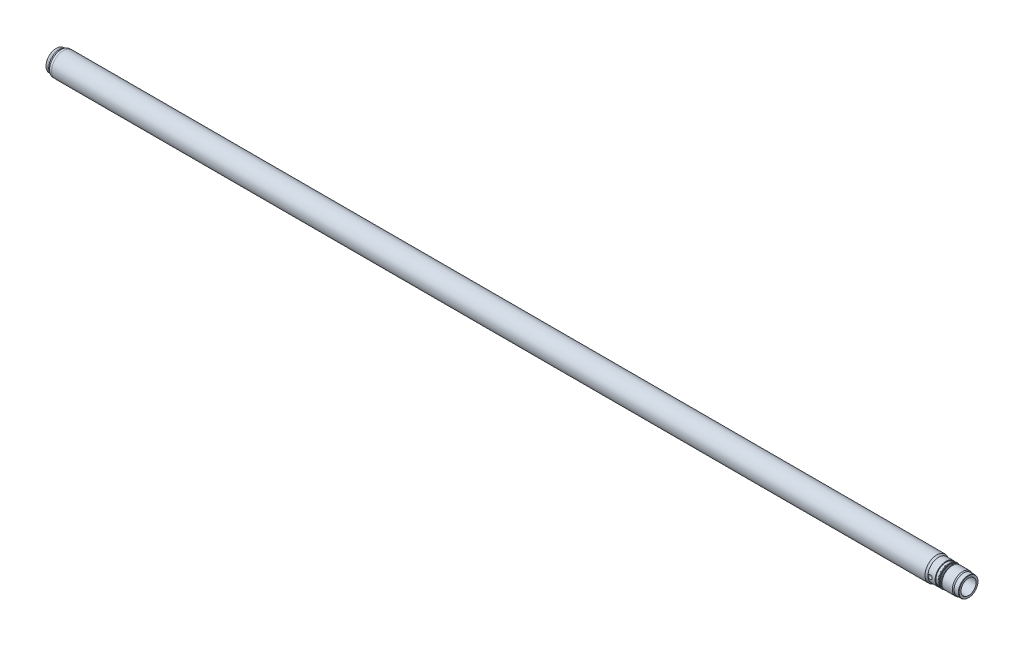
from build123d import *

# Parameters (mm, degrees)
SKETCH2_R          = 4.5
CUT_EXTRUDE1_DEPTH = 50


with BuildPart() as part:
    # Sketch1 → Base-Revolve (revolve)
    with BuildSketch(Plane.XY):
        with BuildLine():
            Line((0, 21), (0, 23.5))
            Line((0, 23.5), (0.5, 24))
            Line((0.5, 24), (5, 24))
            Line((5, 24), (5, 24.75))
            Line((5, 24.75), (7.5, 24.75))
            Line((7.5, 24.75), (11.830127019, 27.25))
            Line((11.830127019, 27.25), (17, 27.25))
            Line((17, 27.25), (17, 27.5))
            Line((17, 27.5), (2038.669872981, 27.5))
            Line((2038.669872981, 27.5), (2043, 25))
            Line((2043, 25), (2059.5, 25))
            ThreePointArc((2059.5, 25), (2059.853553391, 24.853553391), (2060, 24.5))
            Line((2060, 24.5), (2060, 23.5))
            Line((2060, 23.5), (2066, 23.5))
            Line((2066, 23.5), (2066, 24.5))
            ThreePointArc((2066, 24.5), (2066.146446609, 24.853553391), (2066.5, 25))
            Line((2066.5, 25), (2068, 25))
            Line((2068, 25), (2069, 24.422649731))
            Line((2069, 24.422649731), (2069, 23.75))
            ThreePointArc((2069, 23.75), (2069.292893219, 23.042893219), (2070, 22.75))
            Line((2070, 22.75), (2072, 22.75))
            Line((2072, 22.75), (2074.453263132, 24))
            Line((2074.453263132, 24), (2098.401923789, 24))
            Line((2098.401923789, 24), (2101, 22.5))
            Line((2101, 22.5), (2111, 22.5))
            Line((2111, 22.5), (2112, 21.922649731))
            Line((2112, 21.922649731), (2112, 17.5))
            Line((2112, 17.5), (6.062177826, 17.5))
            Line((6.062177826, 17.5), (0, 21))
        make_face()
    revolve(axis=Axis((0, 0, 0), (1, 0, 0)))

    # Sketch2 → Cut-Extrude1 (cut, symmetric)
    with BuildSketch(Plane.XY):
        with Locations((2048, 0)):
            Circle(SKETCH2_R)
    extrude(amount=CUT_EXTRUDE1_DEPTH, both=True, mode=Mode.SUBTRACT)


solid = part.part
